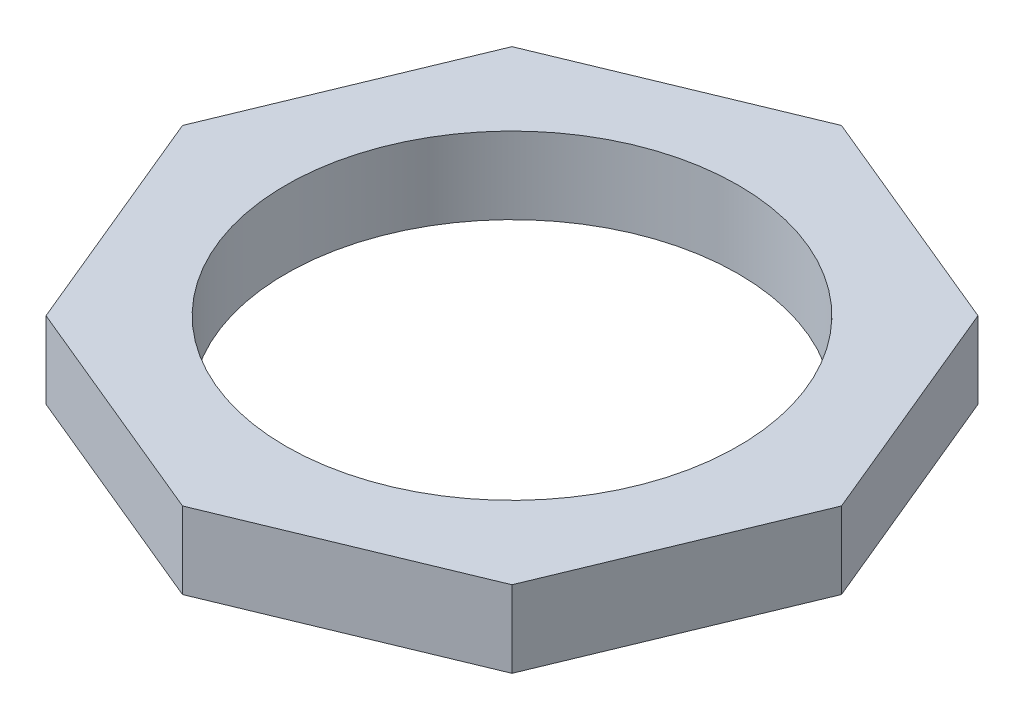
from build123d import *

# Parameters (mm, degrees)
SKETCH1_R           = 42.15
BOSS_EXTRUDE2_DEPTH = 14.3


with BuildPart() as part:
    # Sketch1 → Boss-Extrude2 (new body)
    with BuildSketch(Plane(origin=(0, 0, 0), x_dir=(1, 0, 0), z_dir=(0, 1, 0))):
        Polygon((0, -57.902642122), (43.422338028, -39.916520801), (61.408459349, 3.505817227), (43.422338028, 46.928155255), (0, 64.914276577), (-43.422338028, 46.928155255), (-61.408459349, 3.505817227), (-43.422338028, -39.916520801), align=None)
        with Locations((0, 3.505817227)):
            Circle(SKETCH1_R, mode=Mode.SUBTRACT)
    extrude(amount=BOSS_EXTRUDE2_DEPTH)


solid = part.part
